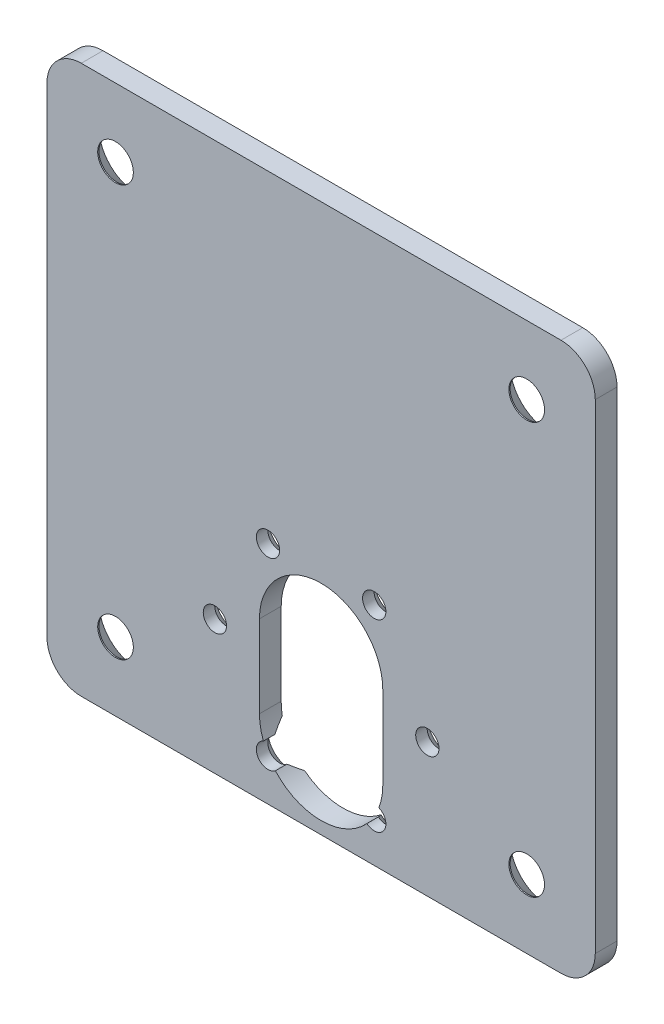
from build123d import *

# Parameters (mm, degrees)
SKETCH1_R           = 2.6
BOSS_EXTRUDE1_DEPTH = 3.175
CHAMFER1_SIZE       = 3
SKETCH4_R           = 1.7
CUT_EXTRUDE2_DEPTH  = 4.175
CHAMFER2_SIZE       = 1.5


with BuildPart() as part:
    # Sketch1 → Boss-Extrude1 (new body)
    with BuildSketch(Plane.XY):
        with BuildLine():
            Line((35, -40), (-35, -40))
            ThreePointArc((-35, -40), (-38.535533906, -38.535533906), (-40, -35))
            Line((-40, -35), (-40, 35))
            ThreePointArc((-40, 35), (-38.535533906, 38.535533906), (-35, 40))
            Line((-35, 40), (35, 40))
            ThreePointArc((35, 40), (38.535533906, 38.535533906), (40, 35))
            Line((40, 35), (40, -35))
            ThreePointArc((40, -35), (38.535533906, -38.535533906), (35, -40))
        make_face()
        with Locations((-30, 30)):
            Circle(SKETCH1_R, mode=Mode.SUBTRACT)
        with Locations((30, 30)):
            Circle(SKETCH1_R, mode=Mode.SUBTRACT)
        with Locations((30, -30)):
            Circle(SKETCH1_R, mode=Mode.SUBTRACT)
        with Locations((-30, -30)):
            Circle(SKETCH1_R, mode=Mode.SUBTRACT)
    extrude(amount=BOSS_EXTRUDE1_DEPTH)

    # Chamfer1
    chamfer1_edges = [part.edges().sort_by_distance(p)[0] for p in [
        (-32.6, 30, 0),
        (27.4, 30, 0),
        (27.4, -30, 0),
        (-32.6, -30, 0),
    ]]
    chamfer(chamfer1_edges, length=CHAMFER1_SIZE)

    # Sketch4 → Cut-Extrude2 (cut, through all)
    with BuildSketch(Plane(origin=(0, 0, 0), x_dir=(-1, 0, 0), z_dir=(0, 0, -1))):
        with Locations((-15.5, -20.5)):
            Circle(SKETCH4_R)
        with Locations((-7.75, -7.076606241)):
            Circle(SKETCH4_R)
        with Locations((7.75, -7.076606241)):
            Circle(SKETCH4_R)
        with Locations((15.5, -20.5)):
            Circle(SKETCH4_R)
        with BuildLine():
            Line((9, -17.202559976), (9, -29.202559976))
            ThreePointArc((9, -29.202559976), (8.855473359, -30.808981962), (8.426535201, -32.363810442))
            ThreePointArc((8.426535201, -32.363810442), (9.201851044, -34.807774076), (6.674545917, -35.23997969))
            ThreePointArc((6.674545917, -35.23997969), (0, -38.202559976), (-6.674545917, -35.23997969))
            ThreePointArc((-6.674545917, -35.23997969), (-9.201851044, -34.807774076), (-8.426535201, -32.363810442))
            ThreePointArc((-8.426535201, -32.363810442), (-8.855473359, -30.808981962), (-9, -29.202559976))
            Line((-9, -29.202559976), (-9, -17.202559976))
            ThreePointArc((-9, -17.202559976), (0, -8.202559976), (9, -17.202559976))
        make_face()
    extrude(amount=-CUT_EXTRUDE2_DEPTH, mode=Mode.SUBTRACT)

    # Chamfer2
    chamfer2_edges = [part.edges().sort_by_distance(p)[0] for p in [
        (17.2, -20.5, 0),
        (9.45, -7.076606241, 0),
        (-13.8, -20.5, 0),
        (9.201851044, -34.807774076, 0),
        (-9.201851044, -34.807774076, 0),
        (-6.05, -7.076606241, 0),
    ]]
    chamfer(chamfer2_edges, length=CHAMFER2_SIZE)


solid = part.part
